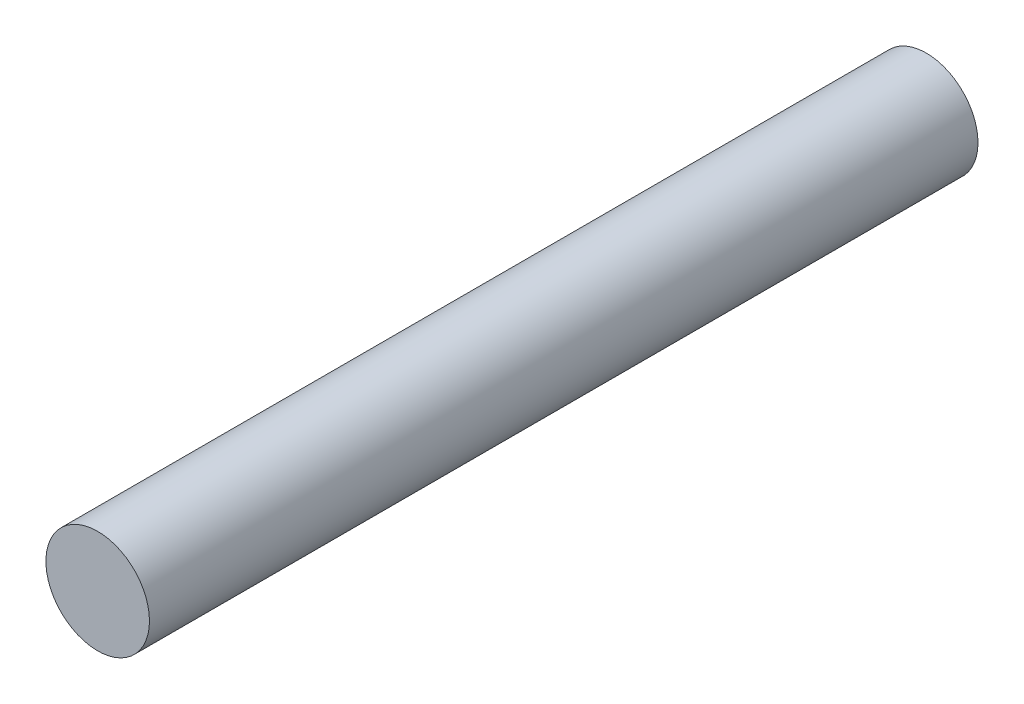
from build123d import *

# Parameters (mm, degrees)
SKETCH1_W = 3.175
SKETCH1_H = 50.8


with BuildPart() as part:
    # Sketch1 → Revolve1 (revolve)
    with BuildSketch(Plane(origin=(0, 0, 0), x_dir=(1, 0, 0), z_dir=(0, 1, 0))):
        with Locations((1.5875, 25.4)):
            Rectangle(SKETCH1_W, SKETCH1_H)
    revolve(axis=Axis((0, 0, 0), (0, 0, -1)))


solid = part.part
